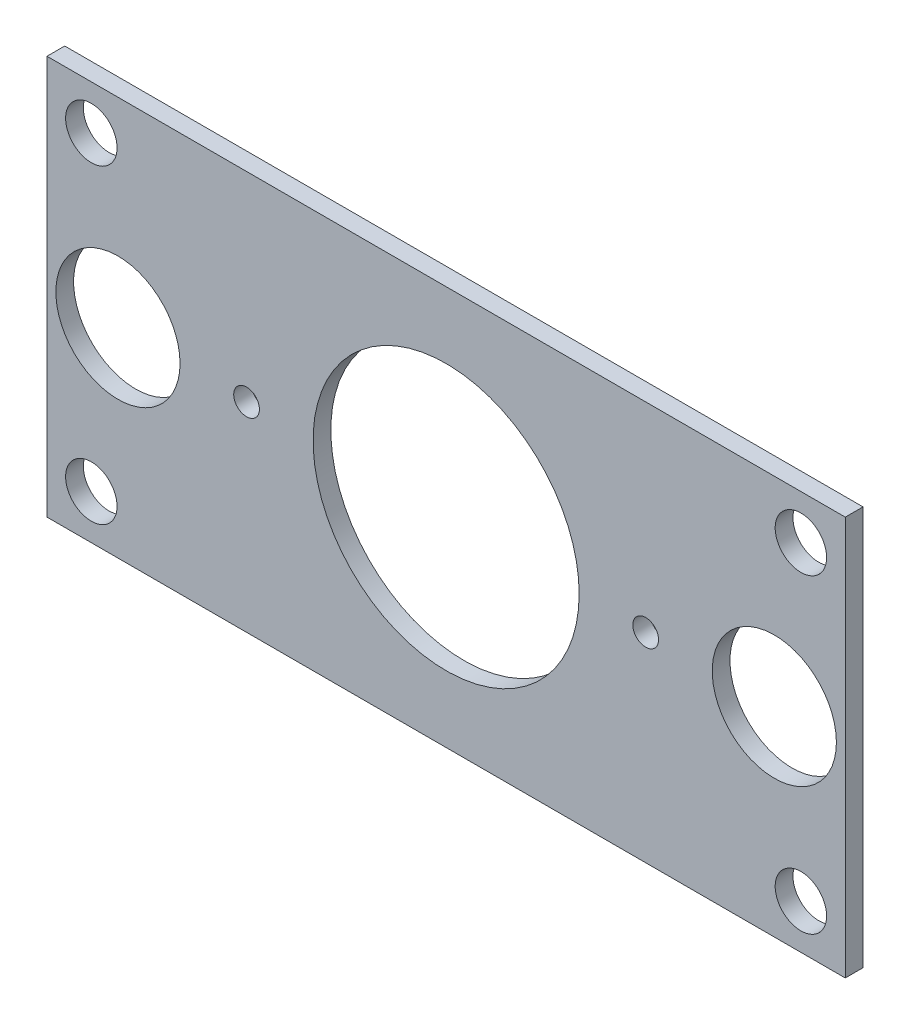
from build123d import *

# Parameters (mm, degrees)
SKETCH_1_W      = 90
SKETCH_1_H      = 45
SKETCH_1_R      = 2.9
SKETCH_1_R_2    = 1.45
SKETCH_1_R_3    = 15
SKETCH_1_R_4    = 7
EXTRUDE_2_DEPTH = 2


with BuildPart() as part:
    # 草图1 → 凸台-拉伸2 (new body)
    with BuildSketch(Plane.XY):
        Rectangle(SKETCH_1_W, SKETCH_1_H)
        with Locations((-40, 17.5)):
            Circle(SKETCH_1_R, mode=Mode.SUBTRACT)
        with Locations((-40, -17.5)):
            Circle(SKETCH_1_R, mode=Mode.SUBTRACT)
        with Locations((40, 17.5)):
            Circle(SKETCH_1_R, mode=Mode.SUBTRACT)
        with Locations((40, -17.5)):
            Circle(SKETCH_1_R, mode=Mode.SUBTRACT)
        with Locations((22.5, 0)):
            Circle(SKETCH_1_R_2, mode=Mode.SUBTRACT)
        with Locations((-22.5, 0)):
            Circle(SKETCH_1_R_2, mode=Mode.SUBTRACT)
        Circle(SKETCH_1_R_3, mode=Mode.SUBTRACT)
        with Locations((-37, 0)):
            Circle(SKETCH_1_R_4, mode=Mode.SUBTRACT)
        with Locations((37, 0)):
            Circle(SKETCH_1_R_4, mode=Mode.SUBTRACT)
    extrude(amount=-EXTRUDE_2_DEPTH)


solid = part.part
